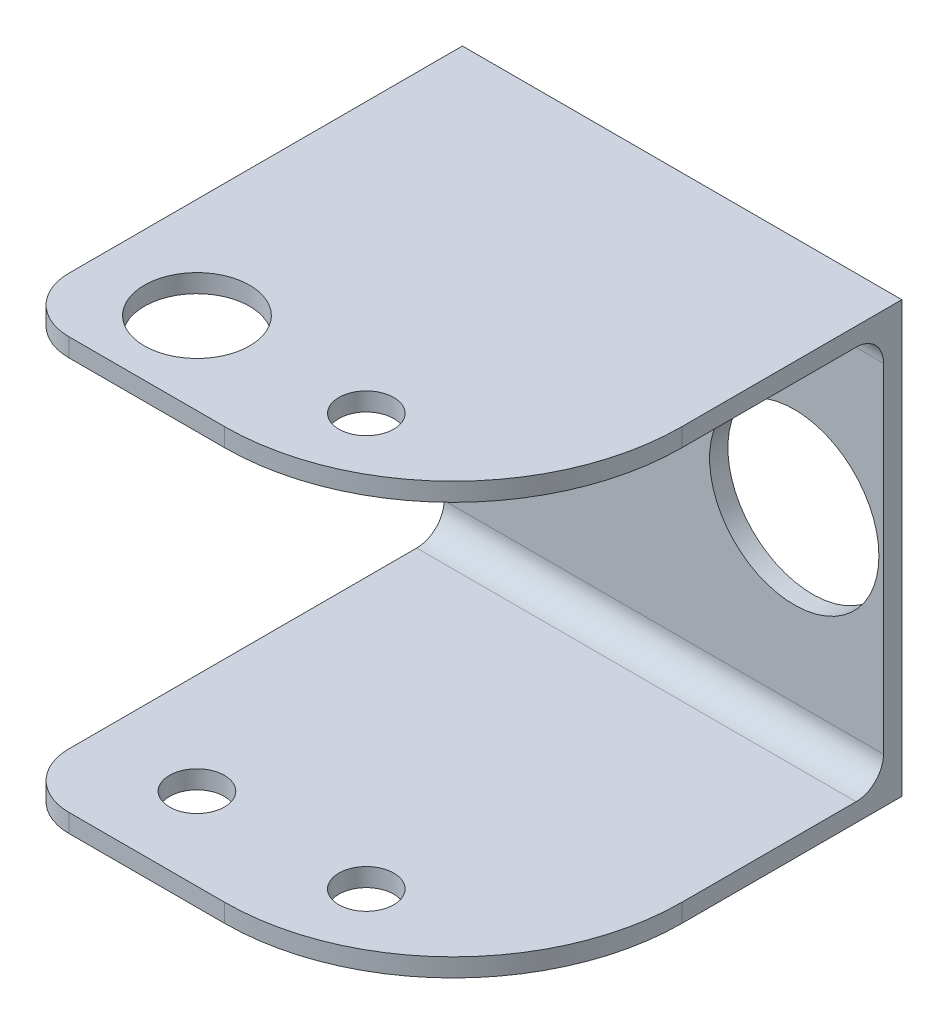
from build123d import *

# Parameters (mm, degrees)
SKETCH1_W           = 48
SKETCH1_H           = 47
BOSS_EXTRUDE1_DEPTH = 49
SKETCH3_W           = 50
SKETCH3_H           = 43
CUT_EXTRUDE1_DEPTH  = 49
SKETCH4_R           = 9.25
CUT_EXTRUDE2_DEPTH  = 2
SKETCH5_R           = 5.75
SKETCH5_R_2         = 3
CUT_EXTRUDE3_DEPTH  = 2
SKETCH7_R           = 3
CUT_EXTRUDE4_DEPTH  = 2
FILLET1_R           = 25
FILLET2_R           = 6
FILLET3_R           = 3


with BuildPart() as part:
    # Sketch1 → Boss-Extrude1 (new body)
    with BuildSketch(Plane.XY):
        Rectangle(SKETCH1_W, SKETCH1_H)
    extrude(amount=BOSS_EXTRUDE1_DEPTH)

    # Sketch3 → Cut-Extrude1 (cut)
    with BuildSketch(Plane(origin=(24, 0, 0), x_dir=(0, 0, -1), z_dir=(1, 0, 0))):
        with Locations((-27, 0)):
            Rectangle(SKETCH3_W, SKETCH3_H)
    extrude(amount=-CUT_EXTRUDE1_DEPTH, mode=Mode.SUBTRACT)

    # Sketch4 → Cut-Extrude2 (cut)
    with BuildSketch(Plane.XY.offset(2)):
        with Locations((14.25, 0)):
            Circle(SKETCH4_R)
    extrude(amount=-CUT_EXTRUDE2_DEPTH, mode=Mode.SUBTRACT)

    # Sketch5 → Cut-Extrude3 (cut)
    with BuildSketch(Plane(origin=(0, 23.5, 0), x_dir=(1, 0, 0), z_dir=(0, 1, 0))):
        with Locations((-13, -40)):
            Circle(SKETCH5_R)
        with Locations((5.5, -40)):
            Circle(SKETCH5_R_2)
    extrude(amount=-CUT_EXTRUDE3_DEPTH, mode=Mode.SUBTRACT)

    # Sketch7 → Cut-Extrude4 (cut)
    with BuildSketch(Plane(origin=(0, -21.5, 0), x_dir=(1, 0, 0), z_dir=(0, 1, 0))):
        with Locations((5.5, -40)):
            Circle(SKETCH7_R)
        with Locations((-13, -40)):
            Circle(SKETCH7_R)
    extrude(amount=-CUT_EXTRUDE4_DEPTH, mode=Mode.SUBTRACT)

    # Fillet1
    fillet1_edges = [part.edges().sort_by_distance(p)[0] for p in [
        (24, 22.5, 49),
        (24, -22.5, 49),
    ]]
    fillet(fillet1_edges, radius=FILLET1_R)

    # Fillet2
    fillet2_edges = [part.edges().sort_by_distance(p)[0] for p in [
        (-24, 22.5, 49),
        (-24, -22.5, 49),
    ]]
    fillet(fillet2_edges, radius=FILLET2_R)

    # Fillet3
    fillet3_edges = [part.edges().sort_by_distance(p)[0] for p in [
        (0, 21.5, 2),
        (0, -21.5, 2),
    ]]
    fillet(fillet3_edges, radius=FILLET3_R)


solid = part.part
